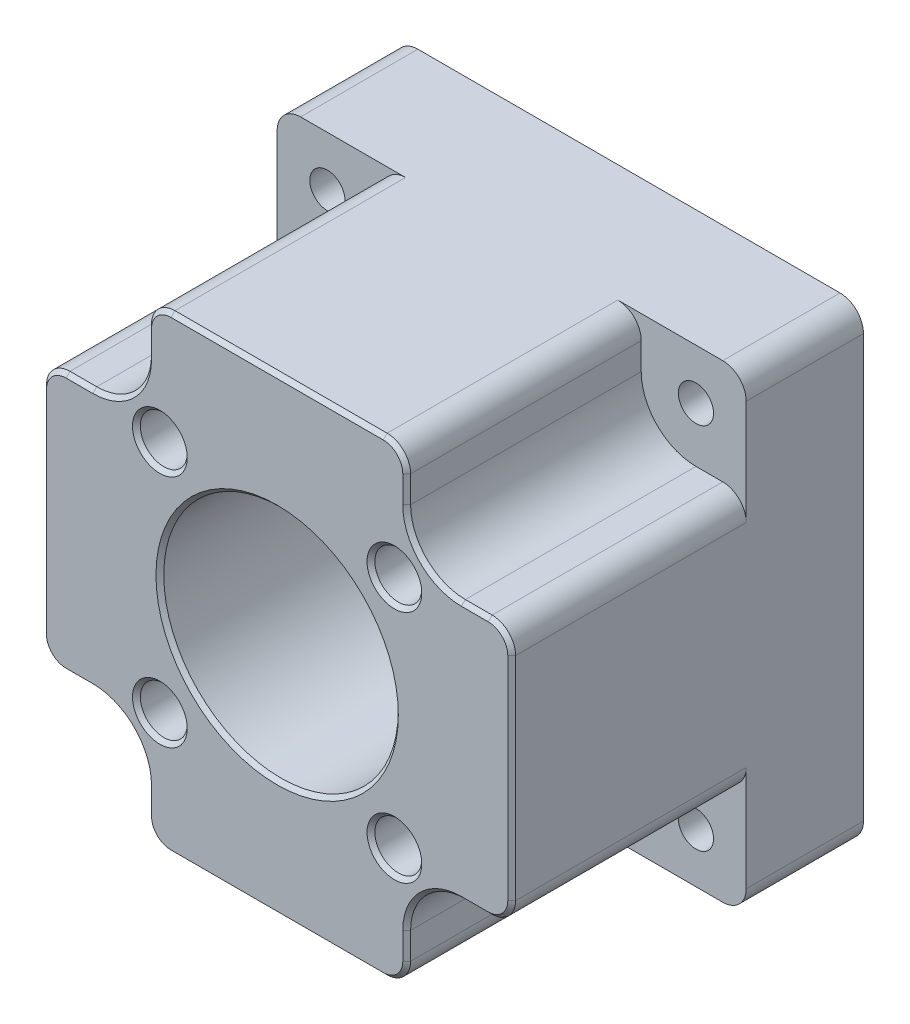
from build123d import *

# Parameters (mm, degrees)
SKETCH1_W                = 60
SKETCH1_H                = 60
BOSS_EXTRUDE1_DEPTH      = 45
CUT_EXTRUDE1_DEPTH       = 30
FILLET1_R                = 3
SKETCH4_R                = 15
CUT_EXTRUDE2_DEPTH       = 46
M4_CLEARANCE_HOLE1_D     = 4.5
M4_CLEARANCE_HOLE1_DEPTH = 15
SKETCH6_R                = 3
CUT_EXTRUDE3_DEPTH       = 20
FILLET2_R                = 3
CHAMFER1_SIZE            = 0.5


with BuildPart() as part:
    # Sketch1 → Boss-Extrude1 (new body)
    with BuildSketch(Plane.XY):
        Rectangle(SKETCH1_W, SKETCH1_H)
    extrude(amount=BOSS_EXTRUDE1_DEPTH)

    # Sketch3 → Cut-Extrude1 (cut)
    with BuildSketch(Plane.XY.offset(45)):
        with BuildLine():
            ThreePointArc((-23.5712, 16.5712), (-18.621452532, 18.621452532), (-16.5712, 23.5712))
            Line((-16.5712, 23.5712), (-16.5712, 30))
            Line((-16.5712, 30), (-30, 30))
            Line((-30, 30), (-30, 16.5712))
            Line((-30, 16.5712), (-23.5712, 16.5712))
        make_face()
        with BuildLine():
            Line((30, 30), (16.5712, 30))
            Line((16.5712, 30), (16.5712, 23.5712))
            ThreePointArc((16.5712, 23.5712), (18.621452532, 18.621452532), (23.5712, 16.5712))
            Line((23.5712, 16.5712), (30, 16.5712))
            Line((30, 16.5712), (30, 30))
        make_face()
        with BuildLine():
            Line((30, -30), (30, -16.5712))
            Line((30, -16.5712), (23.5712, -16.5712))
            ThreePointArc((23.5712, -16.5712), (18.621452532, -18.621452532), (16.5712, -23.5712))
            Line((16.5712, -23.5712), (16.5712, -30))
            Line((16.5712, -30), (30, -30))
        make_face()
        with BuildLine():
            Line((-23.5712, -16.5712), (-30, -16.5712))
            Line((-30, -16.5712), (-30, -30))
            Line((-30, -30), (-16.5712, -30))
            Line((-16.5712, -30), (-16.5712, -23.5712))
            ThreePointArc((-16.5712, -23.5712), (-18.621452532, -18.621452532), (-23.5712, -16.5712))
        make_face()
    extrude(amount=-CUT_EXTRUDE1_DEPTH, mode=Mode.SUBTRACT)

    # Fillet1
    fillet1_edges = [part.edges().sort_by_distance(p)[0] for p in [
        (-30, 30, 7.5),
        (30, 30, 7.5),
        (30, -30, 7.5),
        (-30, -30, 7.5),
    ]]
    fillet(fillet1_edges, radius=FILLET1_R)

    # Sketch4 → Cut-Extrude2 (cut, through all)
    with BuildSketch(Plane.XY.offset(45)):
        Circle(SKETCH4_R)
    extrude(amount=-CUT_EXTRUDE2_DEPTH, mode=Mode.SUBTRACT)

    # M4 Clearance Hole1
    with Locations(Plane(origin=(-23.5712, 23.5712, 15), x_dir=(1, 0, 0), z_dir=(0, 0, 1))):
        with Locations((0, 0), (47.1424, 0), (47.1424, -47.1424), (0, -47.1424)):
            Hole(M4_CLEARANCE_HOLE1_D / 2, depth=M4_CLEARANCE_HOLE1_DEPTH)

    # Sketch6 → Cut-Extrude3 (cut)
    with BuildSketch(Plane.XY.offset(45)):
        with Locations((-15, 15)):
            Circle(SKETCH6_R)
        with Locations((-15, -15)):
            Circle(SKETCH6_R)
        with Locations((15, -15)):
            Circle(SKETCH6_R)
        with Locations((15, 15)):
            Circle(SKETCH6_R)
    extrude(amount=-CUT_EXTRUDE3_DEPTH, mode=Mode.SUBTRACT)

    # Fillet2
    fillet2_edges = [part.edges().sort_by_distance(p)[0] for p in [
        (-16.5712, 30, 30),
        (-30, 16.5712, 30),
        (30, 16.5712, 30),
        (16.5712, 30, 30),
        (16.5712, -30, 30),
        (30, -16.5712, 30),
        (-30, -16.5712, 30),
        (-16.5712, -30, 30),
    ]]
    fillet(fillet2_edges, radius=FILLET2_R)

    # Chamfer1
    chamfer1_edges = [part.edges().sort_by_distance(p)[0] for p in [
        (-15, 0, 45),
        (-18, 15, 45),
        (-18, -15, 45),
        (12, -15, 45),
        (12, 15, 45),
        (-30, 0, 45),
        (0, -30, 45),
        (30, 0, 45),
        (0, 30, 45),
        (-29.121320344, -15.692520344, 45),
        (-15.692520344, -29.121320344, 45),
        (15.692520344, -29.121320344, 45),
        (29.121320344, -15.692520344, 45),
        (29.121320344, 15.692520344, 45),
        (15.692520344, 29.121320344, 45),
        (-15.692520344, 29.121320344, 45),
        (-29.121320344, 15.692520344, 45),
        (-16.5712, 25.2856, 45),
        (-25.2856, 16.5712, 45),
        (-18.621452532, 18.621452532, 45),
        (18.621452532, 18.621452532, 45),
        (25.2856, 16.5712, 45),
        (16.5712, 25.2856, 45),
        (18.621452532, -18.621452532, 45),
        (16.5712, -25.2856, 45),
        (25.2856, -16.5712, 45),
        (-25.2856, -16.5712, 45),
        (-16.5712, -25.2856, 45),
        (-18.621452532, -18.621452532, 45),
    ]]
    chamfer(chamfer1_edges, length=CHAMFER1_SIZE)


solid = part.part
